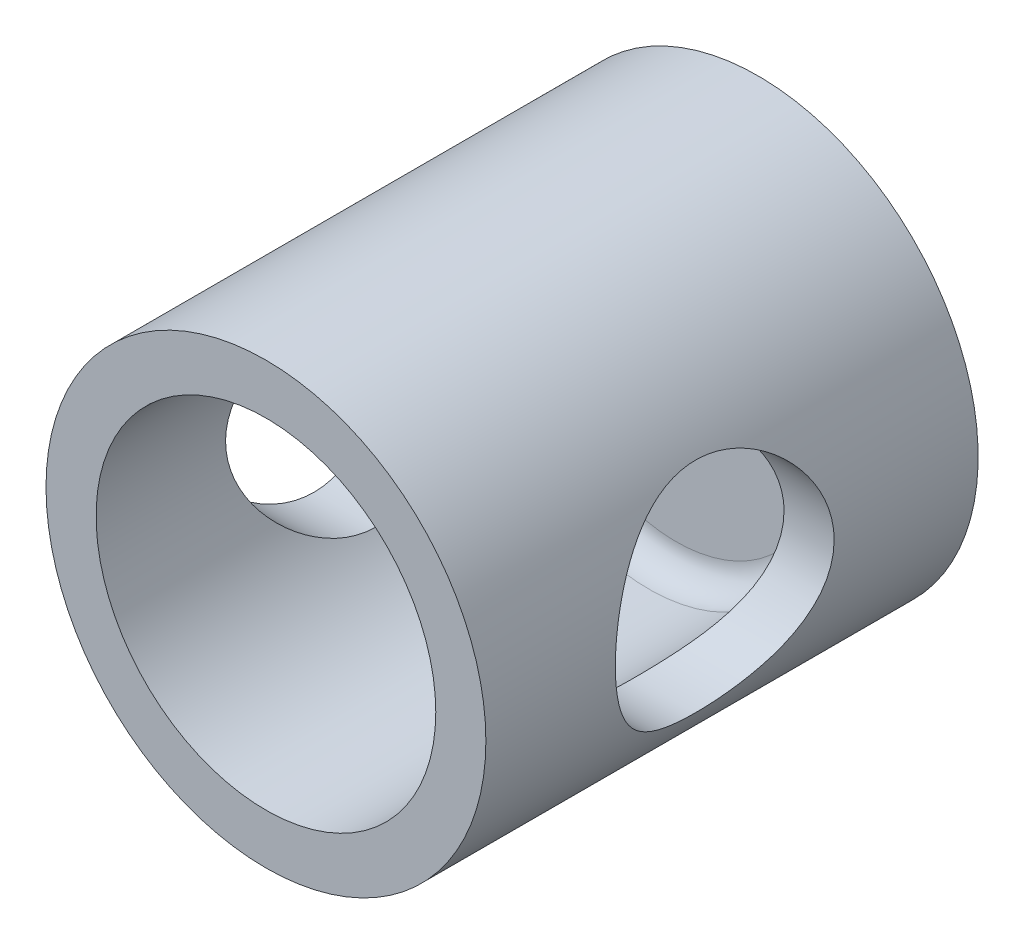
from build123d import *

# Parameters (mm, degrees)
SKETCH2_R               = 10
BOSS_EXTRUDE1_DEPTH     = 18
SKETCH5_R               = 4
CUT_EXTRUDE1_DEPTH      = 18
CUT_EXTRUDE1_DEPTH_BACK = 21
SKETCH6_OUTSIDE_W       = 28.706
SKETCH6_OUTSIDE_H       = 28.706
SKETCH6_OUTSIDE_R       = 8.042126696
CUT_EXTRUDE2_DEPTH      = 24
SKETCH8_R               = 6.210271538
CUT_EXTRUDE4_DEPTH      = 15
FILLET1_R               = 1


with BuildPart() as part:
    # Sketch2 → Boss-Extrude1 (new body)
    with BuildSketch(Plane.XY):
        Circle(SKETCH2_R)
    extrude(amount=BOSS_EXTRUDE1_DEPTH)

    # Sketch5 → Cut-Extrude1 (cut, two sides)
    with BuildSketch(Plane(origin=(0, 0, 0), x_dir=(0, 0, -1), z_dir=(1, 0, 0))) as cut_extrude1_sk:
        with Locations((-9.266027008, 0)):
            Circle(SKETCH5_R)
    extrude(amount=CUT_EXTRUDE1_DEPTH, mode=Mode.SUBTRACT)
    extrude(cut_extrude1_sk.sketch, amount=-CUT_EXTRUDE1_DEPTH_BACK, mode=Mode.SUBTRACT)

    # Sketch6 outside → Cut-Extrude2 (cut)
    with BuildSketch(Plane(origin=(0, 0, 0), x_dir=(-1, 0, 0), z_dir=(0, 0, -1))):
        Rectangle(SKETCH6_OUTSIDE_W, SKETCH6_OUTSIDE_H)
        Circle(SKETCH6_OUTSIDE_R, mode=Mode.SUBTRACT)
    extrude(amount=-CUT_EXTRUDE2_DEPTH, mode=Mode.SUBTRACT)

    # Sketch8 → Cut-Extrude4 (cut)
    with BuildSketch(Plane.XY.offset(18)):
        Circle(SKETCH8_R)
    extrude(amount=-CUT_EXTRUDE4_DEPTH, mode=Mode.SUBTRACT)

    # Fillet1
    fillet1_edges = [part.edges().sort_by_distance(p)[0] for p in [
        (-6.210271538, 0, 3),
    ]]
    fillet(fillet1_edges, radius=FILLET1_R)


solid = part.part
